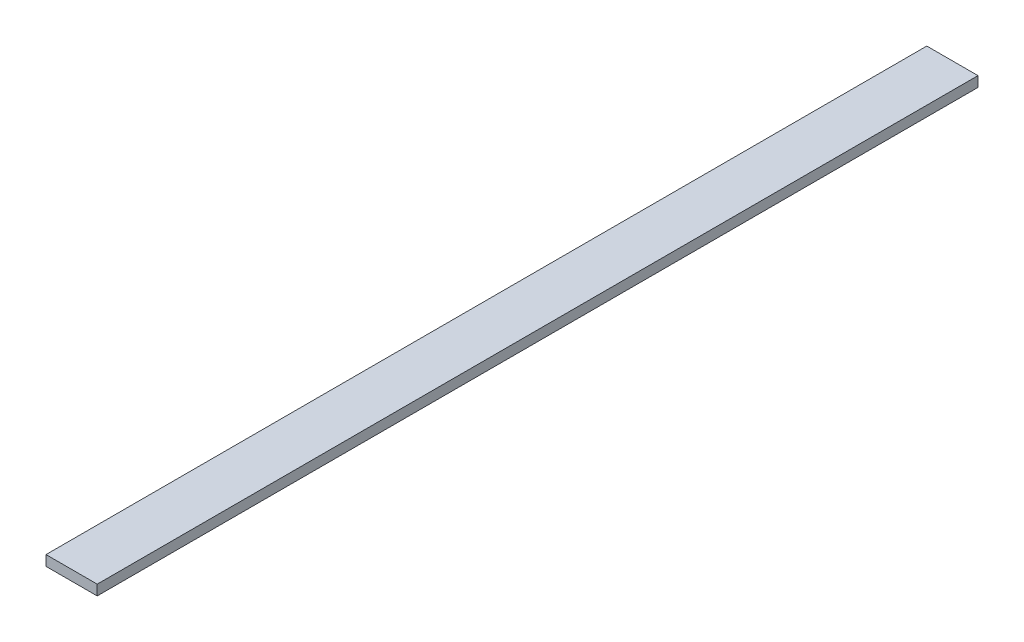
from build123d import *

# Parameters (mm, degrees)
SKETCH1_W           = 50
SKETCH1_H           = 860
BOSS_EXTRUDE1_DEPTH = 10


with BuildPart() as part:
    # Sketch1 → Boss-Extrude1 (new body)
    with BuildSketch(Plane(origin=(0, 0, 0), x_dir=(1, 0, 0), z_dir=(0, 1, 0))):
        with Locations((25, 430)):
            Rectangle(SKETCH1_W, SKETCH1_H)
    extrude(amount=BOSS_EXTRUDE1_DEPTH)


solid = part.part
